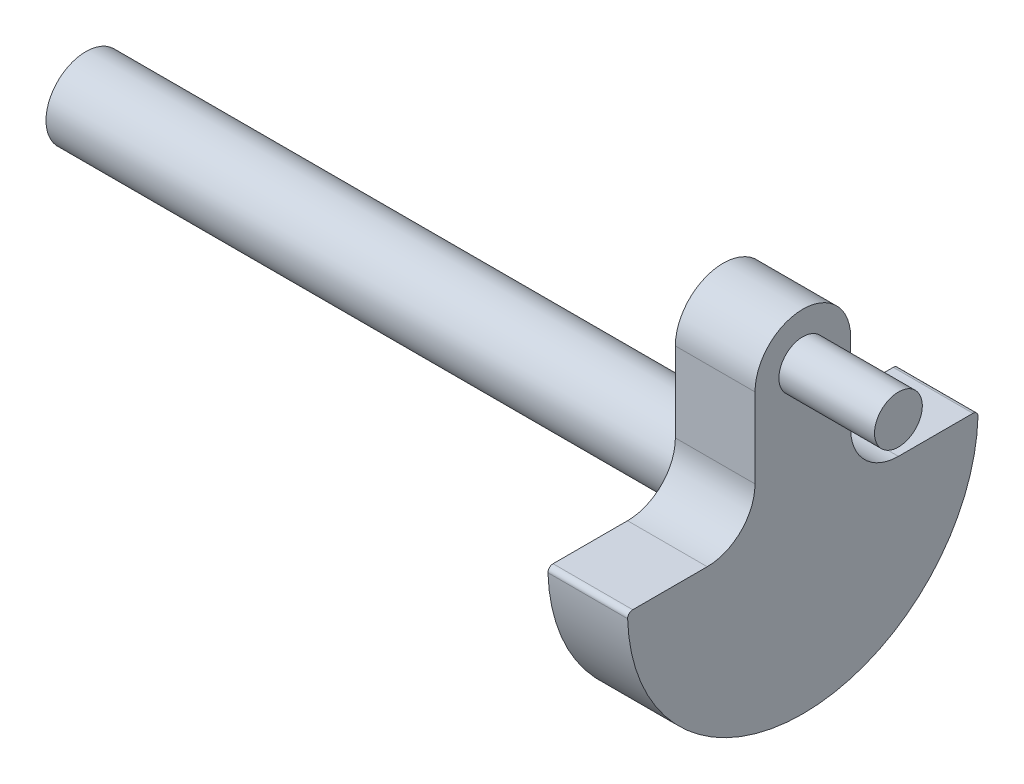
from build123d import *

# Parameters (mm, degrees)
SKETCH2_R           = 1.190625
SKETCH2_R_2         = 1.984375
BOSS_EXTRUDE1_DEPTH = 3.96875
SKETCH3_R           = 1.190625
BOSS_EXTRUDE2_DEPTH = 8.73125
SKETCH4_R           = 1.984375
BOSS_EXTRUDE3_DEPTH = 31.75
SKETCH5_R           = 1.984375
BOSS_EXTRUDE4_DEPTH = 3.96875
FILLET2_R           = 2.38125
FILLET3_R           = 0.254


with BuildPart() as part:
    # Sketch2 → Boss-Extrude1 (new body)
    with BuildSketch(Plane(origin=(0, 0, 0), x_dir=(0, 0, -1), z_dir=(1, 0, 0))):
        with BuildLine():
            Line((8.73125, 0), (2.38125, 0))
            Line((2.38125, 0), (2.38125, 6.35))
            ThreePointArc((2.38125, 6.35), (0, 8.73125), (-2.38125, 6.35))
            Line((-2.38125, 6.35), (-2.38125, 0))
            Line((-2.38125, 0), (-8.73125, 0))
            ThreePointArc((-8.73125, 0), (0, -8.73125), (8.73125, 0))
        make_face()
        with Locations((0, 6.35)):
            Circle(SKETCH2_R, mode=Mode.SUBTRACT)
        Circle(SKETCH2_R_2, mode=Mode.SUBTRACT)
    extrude(amount=BOSS_EXTRUDE1_DEPTH)

    # Sketch3 → Boss-Extrude2 (add)
    with BuildSketch(Plane.ZY):
        with Locations((0, 6.35)):
            Circle(SKETCH3_R)
    extrude(amount=-BOSS_EXTRUDE2_DEPTH)



with BuildPart() as body_2:
    # Sketch4 → Boss-Extrude3 (new body)
    with BuildSketch(Plane.ZY):
        Circle(SKETCH4_R)
    extrude(amount=BOSS_EXTRUDE3_DEPTH)


with BuildPart() as part_1:
    add(part.part)

    add(body_2.part)  # Boss-Extrude4 merges body 2
    # Sketch5 → Boss-Extrude4 (add)
    with BuildSketch(Plane(origin=(0, 0, 0), x_dir=(0, 0, -1), z_dir=(1, 0, 0))):
        Circle(SKETCH5_R)
    extrude(amount=BOSS_EXTRUDE4_DEPTH)

    # Fillet2
    fillet2_edges = [part_1.edges().sort_by_distance(p)[0] for p in [
        (1.984375, 0, -2.38125),
        (1.984375, 0, 2.38125),
    ]]
    fillet(fillet2_edges, radius=FILLET2_R)

    # Fillet3
    fillet3_edges = [part_1.edges().sort_by_distance(p)[0] for p in [
        (1.984375, 0, -8.73125),
        (1.984375, 0, 8.73125),
    ]]
    fillet(fillet3_edges, radius=FILLET3_R)


solid = part_1.part
